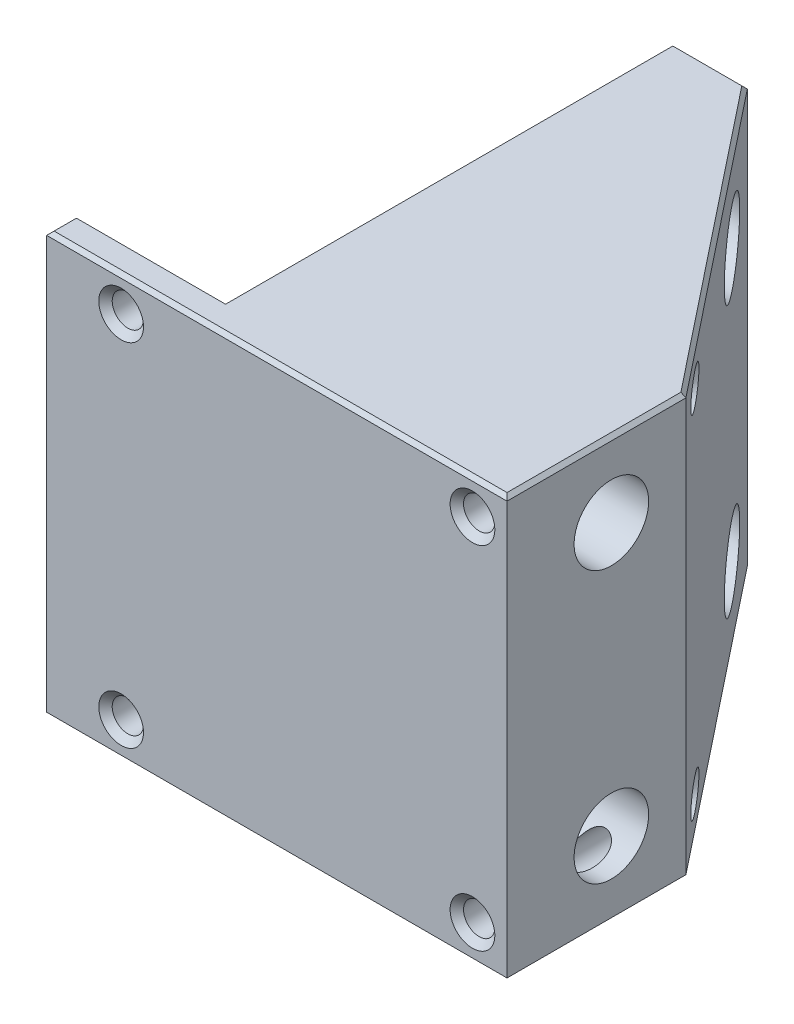
from build123d import *

# Parameters (mm, degrees)
SKETCH1_W                       = 61.76
SKETCH1_H                       = 56.4
BOSS_EXTRUDE1_DEPTH             = 4
M5X0_8_TAPPED_HOLE1_D           = 4.2
M5X0_8_TAPPED_HOLE1_CSINK_D     = 6
M5X0_8_TAPPED_HOLE1_CSINK_ANGLE = 90
SKETCH37_W                      = 41.76
SKETCH37_H                      = 56.4
SKETCH37_R                      = 2.1
BOSS_EXTRUDE7_DEPTH             = 60
CUT_EXTRUDE2_DEPTH              = 57.4
CBORE_FOR_M5_SHCS3_D            = 5.5
CBORE_FOR_M5_SHCS3_CBORE_D      = 10
CBORE_FOR_M5_SHCS3_CBORE_DEPTH  = 36.7
CHAMFER7_SIZE                   = 0.5


with BuildPart() as part:
    # Sketch1 → Boss-Extrude1 (new body)
    with BuildSketch(Plane.XY):
        Rectangle(SKETCH1_W, SKETCH1_H)
    extrude(amount=BOSS_EXTRUDE1_DEPTH)

    # M5x0.8 Tapped Hole1 (through all)
    with Locations(Plane.XY.offset(4)):
        with Locations((26.245, 23.565), (26.245, -23.565), (-20.885, -23.565), (-20.885, 23.565)):
            CounterSinkHole(M5X0_8_TAPPED_HOLE1_D / 2, M5X0_8_TAPPED_HOLE1_CSINK_D / 2, counter_sink_angle=M5X0_8_TAPPED_HOLE1_CSINK_ANGLE)

    # Sketch37 → Boss-Extrude7 (add)
    with BuildSketch(Plane(origin=(0, 0, 0), x_dir=(-1, 0, 0), z_dir=(0, 0, -1))):
        with Locations((-10, 0)):
            Rectangle(SKETCH37_W, SKETCH37_H)
        with Locations((-26.245, 23.565)):
            Circle(SKETCH37_R, mode=Mode.SUBTRACT)
        with Locations((-26.245, -23.565)):
            Circle(SKETCH37_R, mode=Mode.SUBTRACT)
    extrude(amount=BOSS_EXTRUDE7_DEPTH)

    # Sketch40 → Cut-Extrude2 (cut, through all)
    with BuildSketch(Plane.XZ.offset(28.2)):
        Polygon((-0.88, -60), (30.88, -20), (30.88, -60), align=None)
    extrude(amount=-CUT_EXTRUDE2_DEPTH, mode=Mode.SUBTRACT)

    # CBORE for M5 SHCS3 (through all)
    with Locations(Plane(origin=(30.88, 0, 0), x_dir=(0, 0, -1), z_dir=(1, 0, 0))):
        with Locations((10, -18.2), (10, 18.2), (50, 18.2), (50, -18.2)):
            CounterBoreHole(CBORE_FOR_M5_SHCS3_D / 2, CBORE_FOR_M5_SHCS3_CBORE_D / 2, CBORE_FOR_M5_SHCS3_CBORE_DEPTH)

    # Chamfer7
    chamfer7_edges = [part.edges().sort_by_distance(p)[0] for p in [
        (0, -28.2, 4),
        (-20.88, 28.2, 0),
        (-5.88, 28.2, -60),
        (-10.88, -28.2, -30),
        (-10.88, 28.2, -30),
        (-20.88, -28.2, 0),
        (-5.88, -28.2, -60),
        (15, 28.2, -40),
        (15, -28.2, -40),
        (30.88, -28.2, -8),
        (-30.88, -28.2, 2),
        (-30.88, 28.2, 2),
        (30.88, 28.2, -8),
        (0, 28.2, 4),
    ]]
    chamfer(chamfer7_edges, length=CHAMFER7_SIZE)


solid = part.part
